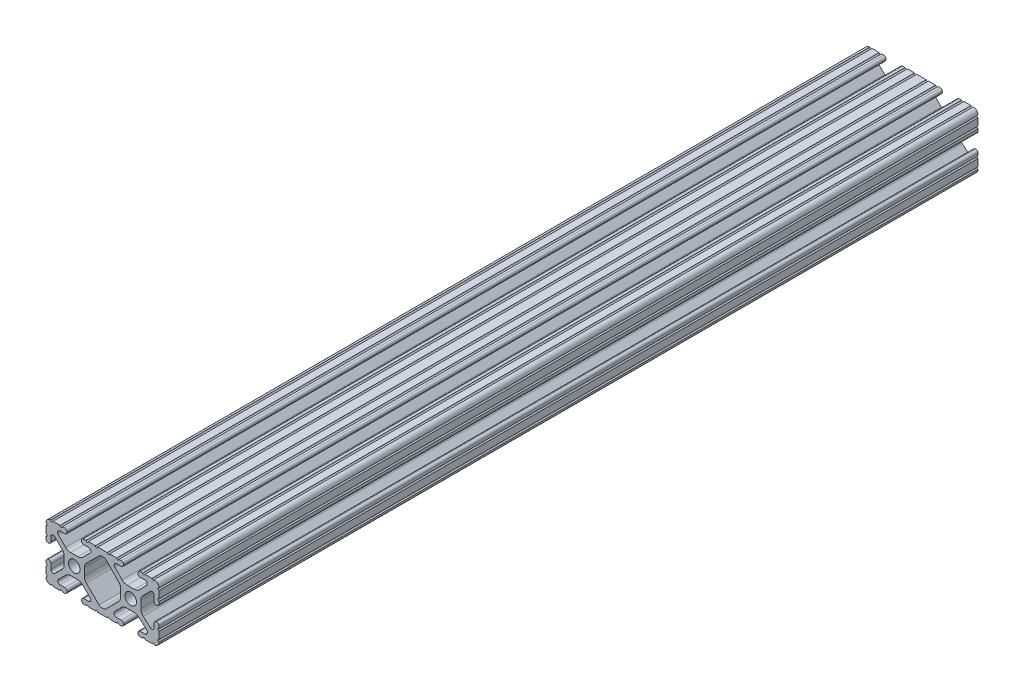
from build123d import *

# Parameters (mm, degrees)
SKETCH1_R           = 2.6035
BOSS_EXTRUDE1_DEPTH = 184.15


with BuildPart() as part:
    # Sketch1 → Boss-Extrude1 (new body, symmetric)
    with BuildSketch(Plane.XY):
        with BuildLine():
            Line((18.01710265, 12.7), (16.98745015, 12.7))
            ThreePointArc((16.98745015, 12.7), (16.245730386, 12.392769614), (15.9385, 11.65104985))
            Line((15.9385, 11.65104985), (15.9385, 11.53922))
            ThreePointArc((15.9385, 11.53922), (16.245750844, 10.797450844), (16.98752, 10.4902))
            Line((16.98752, 10.4902), (19.116384363, 10.4902))
            ThreePointArc((19.116384363, 10.4902), (20.052502933, 9.869096983), (19.844087081, 8.765172272))
            Line((19.844087081, 8.765172272), (16.618993479, 5.455112286))
            ThreePointArc((16.618993479, 5.455112286), (15.578994274, 4.745442459), (14.344932584, 4.4958))
            Line((14.344932584, 4.4958), (11.083317835, 4.4958))
            ThreePointArc((11.083317835, 4.4958), (9.854330953, 4.743306833), (8.816955189, 5.447238587))
            Line((8.816955189, 5.447238587), (5.564154119, 8.762652677))
            ThreePointArc((5.564154119, 8.762652677), (5.352591412, 9.867473037), (6.289393385, 10.4902))
            Line((6.289393385, 10.4902), (8.41248, 10.4902))
            ThreePointArc((8.41248, 10.4902), (9.154249156, 10.797450844), (9.4615, 11.53922))
            Line((9.4615, 11.53922), (9.4615, 11.65104985))
            ThreePointArc((9.4615, 11.65104985), (9.154269614, 12.392769614), (8.41254985, 12.7))
            Line((8.41254985, 12.7), (7.38288465, 12.7))
            ThreePointArc((7.38288465, 12.7), (6.87488465, 12.192), (6.36688465, 12.7))
            Line((6.36688465, 12.7), (3.14958095, 12.7))
            ThreePointArc((3.14958095, 12.7), (2.64158095, 12.192), (2.13358095, 12.7))
            Line((2.13358095, 12.7), (-2.13358095, 12.7))
            ThreePointArc((-2.13358095, 12.7), (-2.64158095, 12.192), (-3.14958095, 12.7))
            Line((-3.14958095, 12.7), (-6.36689735, 12.7))
            ThreePointArc((-6.36689735, 12.7), (-6.87489735, 12.192), (-7.38289735, 12.7))
            Line((-7.38289735, 12.7), (-8.41254985, 12.7))
            ThreePointArc((-8.41254985, 12.7), (-9.154269614, 12.392769614), (-9.4615, 11.65104985))
            Line((-9.4615, 11.65104985), (-9.4615, 11.53922))
            ThreePointArc((-9.4615, 11.53922), (-9.154249156, 10.797450844), (-8.41248, 10.4902))
            Line((-8.41248, 10.4902), (-6.283641037, 10.4902))
            ThreePointArc((-6.283641037, 10.4902), (-5.297291557, 9.829633109), (-5.532576693, 8.666071843))
            Line((-5.532576693, 8.666071843), (-8.809985098, 5.416263103))
            ThreePointArc((-8.809985098, 5.416263103), (-9.836720513, 4.734920264), (-11.045536121, 4.4958))
            Line((-11.045536121, 4.4958), (-14.354463879, 4.4958))
            ThreePointArc((-14.354463879, 4.4958), (-15.563279487, 4.734920264), (-16.590014902, 5.416263103))
            Line((-16.590014902, 5.416263103), (-19.867423307, 8.666071843))
            ThreePointArc((-19.867423307, 8.666071843), (-20.102708443, 9.829633109), (-19.116358963, 10.4902))
            Line((-19.116358963, 10.4902), (-16.98752, 10.4902))
            ThreePointArc((-16.98752, 10.4902), (-16.245750844, 10.797450844), (-15.9385, 11.53922))
            Line((-15.9385, 11.53922), (-15.9385, 11.65104985))
            ThreePointArc((-15.9385, 11.65104985), (-16.245730386, 12.392769614), (-16.98745015, 12.7))
            Line((-16.98745015, 12.7), (-18.01711535, 12.7))
            ThreePointArc((-18.01711535, 12.7), (-18.52511535, 12.192), (-19.03311535, 12.7))
            Line((-19.03311535, 12.7), (-22.2504, 12.7))
            ThreePointArc((-22.2504, 12.7), (-22.758323491, 12.192000006), (-23.266399977, 12.699846982))
            ThreePointArc((-23.266399977, 12.699846982), (-24.782522516, 12.082522516), (-25.399846982, 10.566399977))
            ThreePointArc((-25.399846982, 10.566399977), (-24.892000006, 10.058323491), (-25.4, 9.5504))
            Line((-25.4, 9.5504), (-25.4, 6.3330836))
            ThreePointArc((-25.4, 6.3330836), (-24.892, 5.8250836), (-25.4, 5.3170836))
            Line((-25.4, 5.3170836), (-25.4, 4.237520184))
            ThreePointArc((-25.4, 4.237520184), (-25.107393763, 3.531106237), (-24.400979816, 3.2385))
            Line((-24.400979816, 3.2385), (-24.23922, 3.2385))
            ThreePointArc((-24.23922, 3.2385), (-23.497450844, 3.545750844), (-23.1902, 4.28752))
            Line((-23.1902, 4.28752), (-23.1902, 6.334741132))
            ThreePointArc((-23.1902, 6.334741132), (-22.556026952, 7.286023527), (-21.434002553, 7.066535717))
            Line((-21.434002553, 7.066535717), (-18.147950853, 3.808156468))
            ThreePointArc((-18.147950853, 3.808156468), (-17.452759693, 2.774838327), (-17.208501877, 1.553619571))
            Line((-17.208501877, 1.553619571), (-17.208501877, -1.695179196))
            ThreePointArc((-17.208501877, -1.695179196), (-17.450738657, -2.911536421), (-18.140486065, -3.942289578))
            Line((-18.140486065, -3.942289578), (-21.431579576, -7.227386226))
            ThreePointArc((-21.431579576, -7.227386226), (-22.55444896, -7.449940594), (-23.1902, -6.498002195))
            Line((-23.1902, -6.498002195), (-23.1902, -4.28752))
            ThreePointArc((-23.1902, -4.28752), (-23.497450844, -3.545750844), (-24.23922, -3.2385))
            Line((-24.23922, -3.2385), (-24.35098, -3.2385))
            ThreePointArc((-24.35098, -3.2385), (-25.092749156, -3.545750844), (-25.4, -4.28752))
            Line((-25.4, -4.28752), (-25.4, -5.3171344))
            ThreePointArc((-25.4, -5.3171344), (-24.892, -5.8251344), (-25.4, -6.3331344))
            Line((-25.4, -6.3331344), (-25.4, -9.5504))
            ThreePointArc((-25.4, -9.5504), (-24.892000006, -10.058323491), (-25.399846982, -10.566399977))
            ThreePointArc((-25.399846982, -10.566399977), (-24.782522516, -12.082522516), (-23.266399977, -12.699846982))
            ThreePointArc((-23.266399977, -12.699846982), (-22.758323491, -12.192000006), (-22.2504, -12.7))
            Line((-22.2504, -12.7), (-19.03308995, -12.7))
            ThreePointArc((-19.03308995, -12.7), (-18.52508995, -12.192), (-18.01708995, -12.7))
            Line((-18.01708995, -12.7), (-16.9874692, -12.7))
            ThreePointArc((-16.9874692, -12.7), (-16.245700044, -12.392749156), (-15.9384492, -11.65098))
            Line((-15.9384492, -11.65098), (-15.9384492, -11.53922))
            ThreePointArc((-15.9384492, -11.53922), (-16.245700044, -10.797450844), (-16.9874692, -10.4902))
            Line((-16.9874692, -10.4902), (-19.116358963, -10.4902))
            ThreePointArc((-19.116358963, -10.4902), (-20.055197748, -9.862578342), (-19.834124023, -8.755124678))
            Line((-19.834124023, -8.755124678), (-16.49660751, -5.423689618))
            ThreePointArc((-16.49660751, -5.423689618), (-15.467274017, -4.736928798), (-14.253591699, -4.4958))
            Line((-14.253591699, -4.4958), (-11.146408301, -4.4958))
            ThreePointArc((-11.146408301, -4.4958), (-9.932725983, -4.736928798), (-8.90339249, -5.423689618))
            Line((-8.90339249, -5.423689618), (-5.565875977, -8.755124678))
            ThreePointArc((-5.565875977, -8.755124678), (-5.344802252, -9.862578342), (-6.283641037, -10.4902))
            Line((-6.283641037, -10.4902), (-8.4125308, -10.4902))
            ThreePointArc((-8.4125308, -10.4902), (-9.154299956, -10.797450844), (-9.4615508, -11.53922))
            Line((-9.4615508, -11.53922), (-9.4615508, -11.65098))
            ThreePointArc((-9.4615508, -11.65098), (-9.154299956, -12.392749156), (-8.4125308, -12.7))
            Line((-8.4125308, -12.7), (-7.38287195, -12.7))
            ThreePointArc((-7.38287195, -12.7), (-6.87487195, -12.192), (-6.36687195, -12.7))
            Line((-6.36687195, -12.7), (-3.14960635, -12.7))
            ThreePointArc((-3.14960635, -12.7), (-2.64160635, -12.192), (-2.13360635, -12.7))
            Line((-2.13360635, -12.7), (2.13360635, -12.7))
            ThreePointArc((2.13360635, -12.7), (2.64159365, -12.1920127), (3.14958095, -12.7))
            Line((3.14958095, -12.7), (6.36691005, -12.7))
            ThreePointArc((6.36691005, -12.7), (6.87491005, -12.192), (7.38291005, -12.7))
            Line((7.38291005, -12.7), (8.4125308, -12.7))
            ThreePointArc((8.4125308, -12.7), (9.154299956, -12.392749156), (9.4615508, -11.65098))
            Line((9.4615508, -11.65098), (9.4615508, -11.53922))
            ThreePointArc((9.4615508, -11.53922), (9.154299956, -10.797450844), (8.4125308, -10.4902))
            Line((8.4125308, -10.4902), (6.289393385, -10.4902))
            ThreePointArc((6.289393385, -10.4902), (5.231590322, -9.783049717), (5.480677245, -8.535265862))
            Line((5.480677245, -8.535265862), (8.597933595, -5.423689618))
            ThreePointArc((8.597933595, -5.423689618), (9.627267088, -4.736928798), (10.840949406, -4.4958))
            Line((10.840949406, -4.4958), (14.102564155, -4.4958))
            ThreePointArc((14.102564155, -4.4958), (15.215927525, -4.697410182), (16.187895372, -5.276636531))
            Line((16.187895372, -5.276636531), (19.868247549, -8.482246082))
            ThreePointArc((19.868247549, -8.482246082), (20.188435806, -9.746879864), (19.116384363, -10.4902))
            Line((19.116384363, -10.4902), (16.9874692, -10.4902))
            ThreePointArc((16.9874692, -10.4902), (16.245700044, -10.797450844), (15.9384492, -11.53922))
            Line((15.9384492, -11.53922), (15.9384492, -11.65098))
            ThreePointArc((15.9384492, -11.65098), (16.245700044, -12.392749156), (16.9874692, -12.7))
            Line((16.9874692, -12.7), (18.01710265, -12.7))
            ThreePointArc((18.01710265, -12.7), (18.52510265, -12.192), (19.03310265, -12.7))
            Line((19.03310265, -12.7), (22.2504, -12.7))
            ThreePointArc((22.2504, -12.7), (22.758323491, -12.192000006), (23.266399977, -12.699846982))
            ThreePointArc((23.266399977, -12.699846982), (24.782522516, -12.082522516), (25.399846982, -10.566399977))
            ThreePointArc((25.399846982, -10.566399977), (24.892000006, -10.058323492), (25.4, -9.550400001))
            Line((25.4, -9.550400001), (25.4, -6.333083592))
            ThreePointArc((25.4, -6.333083592), (24.892000001, -5.825083593), (25.4, -5.317083593))
            Line((25.4, -5.317083593), (25.4, -4.237520184))
            ThreePointArc((25.4, -4.237520184), (25.107393763, -3.531106237), (24.400979816, -3.2385))
            Line((24.400979816, -3.2385), (24.189220184, -3.2385))
            ThreePointArc((24.189220184, -3.2385), (23.482806237, -3.531106237), (23.1902, -4.237520184))
            Line((23.1902, -4.237520184), (23.1902, -6.155876159))
            ThreePointArc((23.1902, -6.155876159), (22.62232736, -7.038258539), (21.583974541, -6.886926384))
            Line((21.583974541, -6.886926384), (18.29817066, -4.024970844))
            ThreePointArc((18.29817066, -4.024970844), (17.493730985, -2.946044689), (17.208501877, -1.630807374))
            Line((17.208501877, -1.630807374), (17.208501877, 1.630807374))
            ThreePointArc((17.208501877, 1.630807374), (17.442348332, 2.82673414), (18.109440981, 3.846495088))
            Line((18.109440981, 3.846495088), (21.526346532, 7.353420386))
            ThreePointArc((21.526346532, 7.353420386), (22.585896263, 7.574939077), (23.1902, 6.676867167))
            Line((23.1902, 6.676867167), (23.1902, 4.237520184))
            ThreePointArc((23.1902, 4.237520184), (23.482806237, 3.531106237), (24.189220184, 3.2385))
            Line((24.189220184, 3.2385), (24.400979816, 3.2385))
            ThreePointArc((24.400979816, 3.2385), (25.107393763, 3.531106237), (25.4, 4.237520184))
            Line((25.4, 4.237520184), (25.4, 5.3170836))
            ThreePointArc((25.4, 5.3170836), (24.891949193, 5.825134407), (25.4, 6.333185215))
            Line((25.4, 6.333185215), (25.4, 9.550400015))
            ThreePointArc((25.4, 9.550400015), (24.892000013, 10.058323498), (25.399846982, 10.566399977))
            ThreePointArc((25.399846982, 10.566399977), (24.782522516, 12.082522516), (23.266399977, 12.699846982))
            ThreePointArc((23.266399977, 12.699846982), (22.758323491, 12.192000006), (22.2504, 12.7))
            Line((22.2504, 12.7), (19.03310265, 12.7))
            ThreePointArc((19.03310265, 12.7), (18.52510265, 12.192), (18.01710265, 12.7))
        make_face()
        with Locations((-12.7, 0)):
            Circle(SKETCH1_R, mode=Mode.SUBTRACT)
        with Locations((12.7, 0)):
            Circle(SKETCH1_R, mode=Mode.SUBTRACT)
        with BuildLine():
            Line((-7.259513935, -3.869413038), (-1.545748891, -9.572766749))
            ThreePointArc((-1.545748891, -9.572766749), (-1.035199478, -9.913400116), (-0.433213048, -10.033))
            Line((-0.433213048, -10.033), (0.433213048, -10.033))
            ThreePointArc((0.433213048, -10.033), (1.035199478, -9.913400116), (1.545748891, -9.572766749))
            Line((1.545748891, -9.572766749), (7.259513935, -3.869413038))
            ThreePointArc((7.259513935, -3.869413038), (7.949261343, -2.838659881), (8.191498123, -1.622302656))
            Line((8.191498123, -1.622302656), (8.191498123, 1.622302656))
            ThreePointArc((8.191498123, 1.622302656), (7.955573352, 2.823327967), (7.282860769, 3.845864069))
            Line((7.282860769, 3.845864069), (1.675572808, 9.561086461))
            ThreePointArc((1.675572808, 9.561086461), (1.161034429, 9.910236611), (0.551456936, 10.033))
            Line((0.551456936, 10.033), (-0.395199982, 10.033))
            ThreePointArc((-0.395199982, 10.033), (-0.994772524, 9.914396349), (-1.50403329, 9.576450301))
            Line((-1.50403329, 9.576450301), (-7.252049147, 3.876839553))
            ThreePointArc((-7.252049147, 3.876839553), (-7.947240307, 2.843521412), (-8.191498123, 1.622302656))
            Line((-8.191498123, 1.622302656), (-8.191498123, -1.622302656))
            ThreePointArc((-8.191498123, -1.622302656), (-7.949261343, -2.838659881), (-7.259513935, -3.869413038))
        make_face(mode=Mode.SUBTRACT)
    extrude(amount=BOSS_EXTRUDE1_DEPTH, both=True)


solid = part.part
